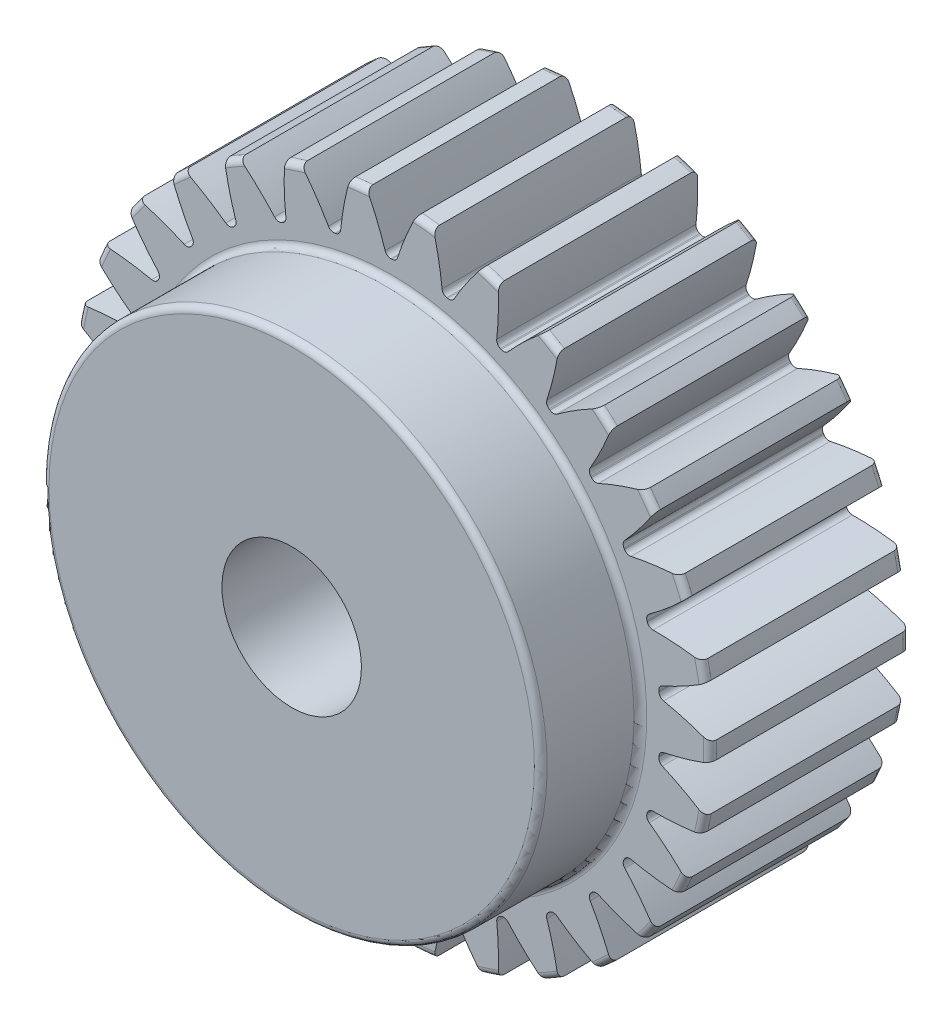
from build123d import *

# Parameters (mm, degrees)
FILLET2_R               = 0.64
CUT_EXTRUDE2_DEPTH      = 21
CIRPATTERN1_COUNT       = 30
SKETCH8_R               = 7
CUT_EXTRUDE3_DEPTH      = 1
CUT_EXTRUDE3_DEPTH_BACK = 31.0000001


with BuildPart() as part:
    # Sketch4 → Revolve1 (revolve)
    with BuildSketch(Plane(origin=(0, 0, 0), x_dir=(0, 0, -1), z_dir=(1, 0, 0))):
        Polygon((-30, 6), (-30, 25), (-20, 25), (-20, 32), (0, 32), (0, 6), align=None)
    revolve(axis=Axis((0, 0, 20), (0, 0, 1)))

    # Fillet2
    fillet2_edges = [part.edges().sort_by_distance(p)[0] for p in [
        (0, -32, 0),
        (0, -32, 20),
        (0, -25, 20),
        (0, -25, 30),
    ]]
    fillet(fillet2_edges, radius=FILLET2_R)

    # Sketch7 → Cut-Extrude2 (cut, through all)
    with BuildSketch(Plane.XY.offset(20)):
        with BuildLine():
            ThreePointArc((-0.051684591, 26.999950531), (0, 27), (0.051684591, 26.999950531))
            ThreePointArc((0.051684591, 26.999950531), (0.405839713, 27.114772712), (0.624097338, 27.416391003))
            ThreePointArc((0.624097338, 27.416391003), (1.460662545, 29.697700431), (2.479107464, 31.903824632))
            ThreePointArc((2.479107464, 31.903824632), (0, 32), (-2.479107464, 31.903824632))
            ThreePointArc((-2.479107464, 31.903824632), (-1.460662545, 29.697700431), (-0.624097338, 27.416391003))
            ThreePointArc((-0.624097338, 27.416391003), (-0.405839713, 27.114772712), (-0.051684591, 26.999950531))
        make_face()
    cut_extrude2 = extrude(amount=-CUT_EXTRUDE2_DEPTH, mode=Mode.SUBTRACT)

    # CirPattern1: Cut-Extrude2 ×30 about axis
    cirpattern1_axis = Axis((0, 0, 0), (0, 0, 1))
    for i in range(1, CIRPATTERN1_COUNT):
        add(cut_extrude2.rotate(cirpattern1_axis, i * 360 / CIRPATTERN1_COUNT), mode=Mode.SUBTRACT)

    # Sketch8 → Cut-Extrude3 (cut, two sides)
    with BuildSketch(Plane.XY.offset(30)) as cut_extrude3_sk:
        Circle(SKETCH8_R)
    extrude(amount=CUT_EXTRUDE3_DEPTH, mode=Mode.SUBTRACT)
    extrude(cut_extrude3_sk.sketch, amount=-CUT_EXTRUDE3_DEPTH_BACK, mode=Mode.SUBTRACT)


solid = part.part
